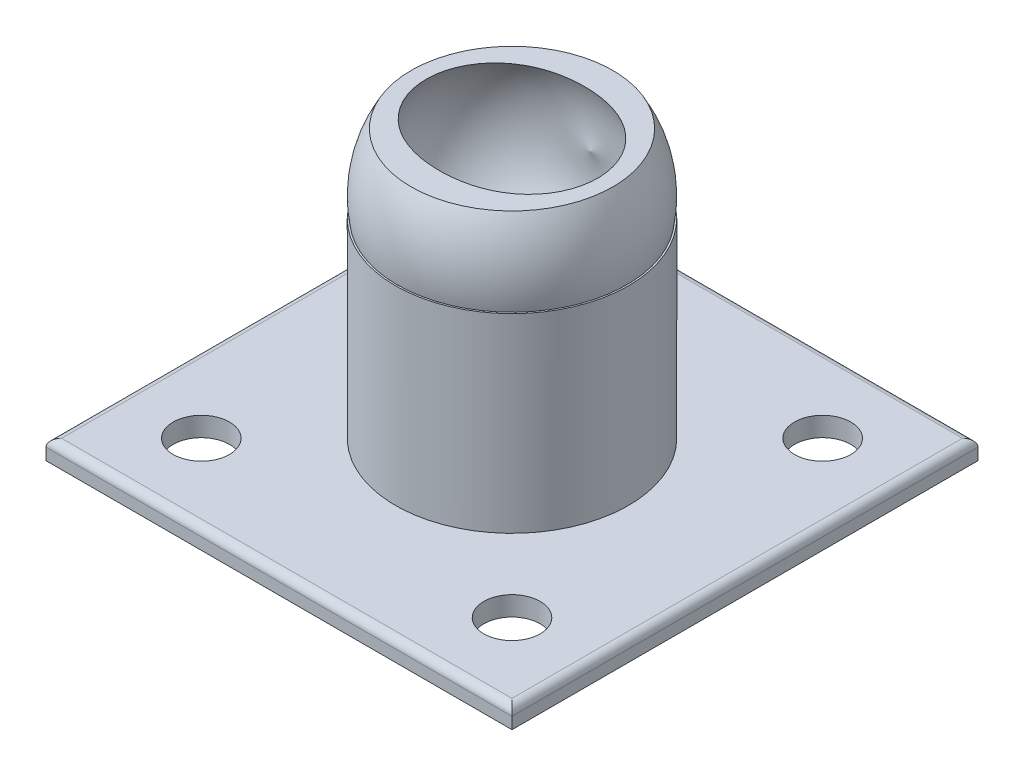
from build123d import *

# Parameters (mm, degrees)
ESQUISSE3_W                  = 120
ESQUISSE3_H                  = 120
BOSS_EXTRU_2_DEPTH           = 5
ESQUISSE5_R                  = 7.25
ENL_V_MAT_EXTRU_1_DEPTH      = 5
ENL_V_START                  = 5
ESQUISSE6_R                  = 7.25
ENL_V_MAT_EXTRU_7_DEPTH      = 5
CONG_4_R                     = 2
ESQUISSE24_R                 = 30
BOSS_EXTRU_6_DEPTH           = 49
ENL_V_MAT_EXTRU_9_DEPTH      = 49
ENL_V_MAT_EXTRU_9_DEPTH_BACK = 39
ESQUISSE25_W                 = 58.572715418
ESQUISSE25_H                 = 23.669871575


with BuildPart() as part:
    # Esquisse3 → Boss.-Extru.2 (new body)
    with BuildSketch(Plane(origin=(0, 0, 0), x_dir=(1, 0, 0), z_dir=(0, 1, 0))):
        Rectangle(ESQUISSE3_W, ESQUISSE3_H)
    extrude(amount=BOSS_EXTRU_2_DEPTH)

    # Esquisse5 → Enlèv. mat.-Extru.1 (cut)
    with BuildSketch(Plane(origin=(0, 5, 0), x_dir=(1, 0, 0), z_dir=(0, 1, 0))):
        with Locations(Location((-40, 40, 0), (0, 0, 270))):
            Circle(ESQUISSE5_R)
    extrude(amount=-ENL_V_MAT_EXTRU_1_DEPTH, mode=Mode.SUBTRACT)

    # Esquisse6 → Enlèv. mat.-Extru.7 (cut)
    with BuildSketch(Plane(origin=(0, 0, 0), x_dir=(1, 0, 0), z_dir=(0, 1, 0)).offset(ENL_V_START)):
        with Locations(Location((-40, 40, 0), (0, 0, 270))):
            Circle(ESQUISSE6_R)
        with Locations(Location((40, 40, 0), (0, 0, 90))):
            Circle(ESQUISSE6_R)
        with Locations(Location((-40, -40, 0), (0, 0, 90))):
            Circle(ESQUISSE6_R)
        with Locations(Location((40, -40, 0), (0, 0, 270))):
            Circle(ESQUISSE6_R)
    extrude(amount=-ENL_V_MAT_EXTRU_7_DEPTH, mode=Mode.SUBTRACT)

    # Congé4
    cong_4_edges = [part.edges().sort_by_distance(p)[0] for p in [
        (60, 5, 0),
        (0, 5, -60),
        (-60, 5, 0),
        (0, 5, 60),
    ]]
    fillet(cong_4_edges, radius=CONG_4_R)



with BuildPart() as body_2:
    # Esquisse19 → Révolution2 (revolve)
    with BuildSketch(Plane(origin=(0, 0, 0), x_dir=(0, 0, -1), z_dir=(1, 0, 0))):
        with BuildLine():
            Line((30, 59.036513732), (-30, 59.036513732))
            ThreePointArc((-30, 59.036513732), (0, 29.036513732), (30, 59.036513732))
        make_face()
    revolve(axis=Axis((0, 59.036513732, -30), (0, 0, 1)))


with BuildPart() as part_1:
    add(part.part)

    add(body_2.part)  # Boss.-Extru.6 merges body 2
    # Esquisse24 → Boss.-Extru.6 (add)
    with BuildSketch(Plane(origin=(0, 5, 0), x_dir=(1, 0, 0), z_dir=(0, 1, 0))):
        with Locations(Location((0, 0, 0), (0, 0, 90))):
            Circle(ESQUISSE24_R)
    extrude(amount=BOSS_EXTRU_6_DEPTH)

    # Esquisse20 → Enlèvement de matière-Révolution5 (revolve, cut)
    with BuildSketch(Plane(origin=(0, 0, 0), x_dir=(0, 0, -1), z_dir=(1, 0, 0))):
        with BuildLine():
            Line((-20, 59.036513732), (20, 59.036513732))
            ThreePointArc((20, 59.036513732), (0, 85.741636789), (-20, 59.036513732))
        make_face()
    revolve(axis=Axis((0, 59.036513732, 20), (0, 0, -1)), mode=Mode.SUBTRACT)

    # Esquisse25 → Enlèv. mat.-Extru.9 (cut, two sides: drawn at the far end of the back side and taken through both)
    with BuildSketch(Plane.XY.offset(-ENL_V_MAT_EXTRU_9_DEPTH_BACK)):
        with Locations((0, 85.882080869)):
            Rectangle(ESQUISSE25_W, ESQUISSE25_H)
    extrude(amount=ENL_V_MAT_EXTRU_9_DEPTH + ENL_V_MAT_EXTRU_9_DEPTH_BACK, mode=Mode.SUBTRACT)


solid = part_1.part
